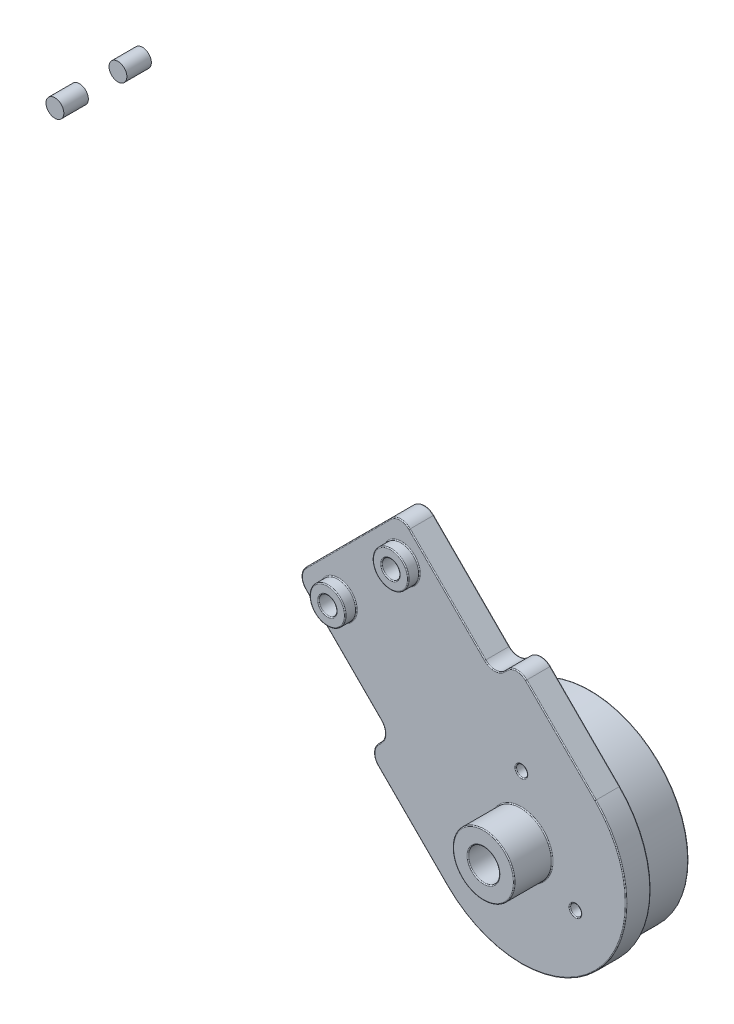
from build123d import *

# Parameters (mm, degrees)
SKETCH3_R               = 1
BOSS_EXTRUDE1_DEPTH     = 2.75
BOSS_EXTRUDE1_2_DEPTH   = 2.75
SKETCH3_R_2             = 10
BOSS_EXTRUDE1_3_DEPTH   = 2.75
SKETCH4_R               = 10
BOSS_EXTRUDE3_DEPTH     = 1
SKETCH5_R               = 11
SKETCH5_R_2             = 10
BOSS_EXTRUDE4_DEPTH     = 5
FILLET1_R               = 1.5
SKETCH6_R               = 2
SKETCH6_R_2             = 1
BOSS_EXTRUDE5_DEPTH     = 1.25
SKETCH7_R               = 1.75
CUT_EXTRUDE1_DEPTH      = 1
SKETCH8_R               = 3.45
SKETCH8_R_2             = 1.75
BOSS_EXTRUDE6_DEPTH     = 4.25
SKETCH9_R               = 0.625
CUT_EXTRUDE2_DEPTH      = 1
FILLET2_R               = 0.1
SKETCH12_R              = 1
CUT_EXTRUDE4_DEPTH      = 8
CUT_EXTRUDE4_DEPTH_BACK = 6.0000001


with BuildPart() as part:
    # Sketch3 → Boss-Extrude1 (new body)
    with BuildSketch(Plane.XY):
        with Locations((47.674098192, 45.254833996)):
            Circle(SKETCH3_R)
    extrude(amount=BOSS_EXTRUDE1_DEPTH)


with BuildPart() as body_2:
    # Sketch3 → Boss-Extrude1 2 (new body)
    with BuildSketch(Plane.XY):
        with Locations((54.745166004, 52.325901808)):
            Circle(SKETCH3_R)
    extrude(amount=BOSS_EXTRUDE1_2_DEPTH)


with BuildPart() as body_3:
    # Sketch3 → Boss-Extrude1 3 (new body)
    with BuildSketch(Plane.XY):
        with BuildLine():
            Line((86.388194462, 25.279067427), (74.720932573, 13.611805538))
            Line((74.720932573, 13.611805538), (85.32753429, 3.00520382))
            Line((85.32753429, 3.00520382), (82.852660556, 0.530330086))
            Line((82.852660556, 0.530330086), (91.691495321, -8.308504679))
            ThreePointArc((91.691495321, -8.308504679), (108.308504679, -8.308504679), (108.308504679, 8.308504679))
            Line((108.308504679, 8.308504679), (99.469669914, 17.147339444))
            Line((99.469669914, 17.147339444), (96.99479618, 14.67246571))
            Line((96.99479618, 14.67246571), (86.388194462, 25.279067427))
        make_face()
        with Locations((100, 0)):
            Circle(SKETCH3_R_2, mode=Mode.SUBTRACT)
    extrude(amount=BOSS_EXTRUDE1_3_DEPTH)

    # Sketch4 → Boss-Extrude3 (add)
    with BuildSketch(Plane.XY.offset(2.75)):
        with Locations((100, 0)):
            Circle(SKETCH4_R)
    extrude(amount=-BOSS_EXTRUDE3_DEPTH)

    # Sketch5 → Boss-Extrude4 (add)
    with BuildSketch(Plane(origin=(0, 0, 0), x_dir=(-1, 0, 0), z_dir=(0, 0, -1))):
        with Locations((-100, 0)):
            Circle(SKETCH5_R)
        with Locations((-100, 0)):
            Circle(SKETCH5_R_2, mode=Mode.SUBTRACT)
    extrude(amount=BOSS_EXTRUDE4_DEPTH)

    # Fillet1
    fillet1_edges = [body_3.edges().sort_by_distance(p)[0] for p in [
        (96.99479618, 14.67246571, 1.375),
        (99.469669914, 17.147339444, 1.375),
        (82.852660556, 0.530330086, 1.375),
        (85.32753429, 3.00520382, 1.375),
        (74.720932573, 13.611805538, 1.375),
        (86.388194462, 25.279067427, 1.375),
    ]]
    fillet(fillet1_edges, radius=FILLET1_R)

    # Sketch6 → Boss-Extrude5 (add)
    with BuildSketch(Plane.XY.offset(2.75)):
        with Locations((86.564971157, 20.506096654)):
            Circle(SKETCH6_R)
        with Locations((86.564971157, 20.506096654)):
            Circle(SKETCH6_R_2, mode=Mode.SUBTRACT)
        with Locations((79.493903346, 13.435028843)):
            Circle(SKETCH6_R)
        with Locations((79.493903346, 13.435028843)):
            Circle(SKETCH6_R_2, mode=Mode.SUBTRACT)
    extrude(amount=BOSS_EXTRUDE5_DEPTH)

    # Sketch7 → Cut-Extrude1 (cut)
    with BuildSketch(Plane.XY.offset(2.75)):
        with Locations((100, 0)):
            Circle(SKETCH7_R)
    extrude(amount=-CUT_EXTRUDE1_DEPTH, mode=Mode.SUBTRACT)

    # Sketch8 → Boss-Extrude6 (add)
    with BuildSketch(Plane.XY.offset(2.75)):
        with Locations((100, 0)):
            Circle(SKETCH8_R)
        with Locations((100, 0)):
            Circle(SKETCH8_R_2, mode=Mode.SUBTRACT)
    extrude(amount=BOSS_EXTRUDE6_DEPTH)

    # Sketch9 → Cut-Extrude2 (cut)
    with BuildSketch(Plane.XY.offset(2.75)):
        with Locations((100, 7)):
            Circle(SKETCH9_R)
        with Locations((106.062177826, -3.5)):
            Circle(SKETCH9_R)
        with Locations((93.937822174, -3.5)):
            Circle(SKETCH9_R)
    extrude(amount=-CUT_EXTRUDE2_DEPTH, mode=Mode.SUBTRACT)

    # Fillet2
    fillet2_edges = [body_3.edges().sort_by_distance(p)[0] for p in [
        (96.55, 0, 7),
        (96.55, 0, 2.75),
        (98.25, 0, 7),
        (99.375, 7, 2.75),
        (99.375, 7, 1.75),
        (105.437177826, -3.5, 2.75),
        (105.437177826, -3.5, 1.75),
        (93.312822174, -3.5, 2.75),
        (93.312822174, -3.5, 1.75),
        (108.308504679, -8.308504679, 2.75),
        (104.419417382, 12.197591975, 2.75),
        (90, 0, 1.75),
        (111, 0, 0),
        (111, 0, -5),
        (110, 0, -5),
        (91.691495321, 19.975766569, 0),
        (91.691495321, 19.975766569, 2.75),
        (98.232233047, 15.909902577, 0),
        (98.232233047, 15.909902577, 2.75),
        (87.802408025, -4.419417382, 0),
        (84.090097423, 1.767766953, 0),
        (80.024233431, 8.308504679, 0),
        (80.554563517, 19.445436483, 0),
        (86.388194462, 24.657747084, 0),
        (75.342252916, 13.611805538, 0),
        (83.4739809, 0.530330086, 0),
        (99.469669914, 16.5260191, 0),
        (80.554563517, 19.445436483, 2.75),
        (80.024233431, 8.308504679, 2.75),
        (84.090097423, 1.767766953, 2.75),
        (87.802408025, -4.419417382, 2.75),
        (86.388194462, 24.657747084, 2.75),
        (75.342252916, 13.611805538, 2.75),
        (83.4739809, 0.530330086, 2.75),
        (99.469669914, 16.5260191, 2.75),
        (96.99479618, 15.293786053, 0),
        (96.99479618, 15.293786053, 2.75),
        (84.706213947, 3.00520382, 0),
        (84.706213947, 3.00520382, 2.75),
        (84.564971157, 20.506096654, 4),
        (84.564971157, 20.506096654, 2.75),
        (85.564971157, 20.506096654, 4),
        (77.493903346, 13.435028843, 4),
        (77.493903346, 13.435028843, 2.75),
        (104.419417382, 12.197591975, 0),
        (78.493903346, 13.435028843, 4),
        (108.308504679, -8.308504679, 0),
        (98.25, 0, 1.75),
    ]]
    fillet(fillet2_edges, radius=FILLET2_R)

    # Sketch12 → Cut-Extrude4 (cut, two sides)
    with BuildSketch(Plane.XY) as cut_extrude4_sk:
        with Locations((86.564971157, 20.506096654)):
            Circle(SKETCH12_R)
        with Locations((79.493903346, 13.435028843)):
            Circle(SKETCH12_R)
    extrude(amount=CUT_EXTRUDE4_DEPTH, mode=Mode.SUBTRACT)
    extrude(cut_extrude4_sk.sketch, amount=-CUT_EXTRUDE4_DEPTH_BACK, mode=Mode.SUBTRACT)


solid = Compound([part.part, body_2.part, body_3.part])
